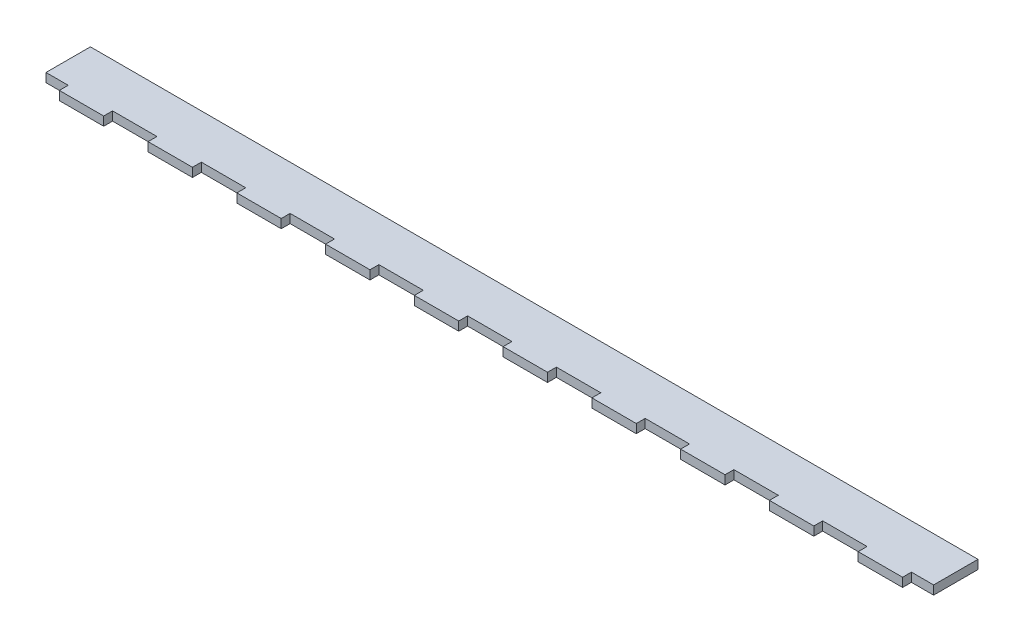
from build123d import *

# Parameters (mm, degrees)
BOSS_EXTRUDE1_DEPTH = 5.08


with BuildPart() as part:
    # Sketch1 → Boss-Extrude1 (new body)
    with BuildSketch(Plane(origin=(0, 0, 0), x_dir=(1, 0, 0), z_dir=(0, 1, 0))):
        Polygon((-190.5, -12.7), (-190.5, -17.78), (-165.1, -17.78), (-165.1, -12.7), (-139.7, -12.7), (-139.7, -17.78), (-114.3, -17.78), (-114.3, -12.7), (-88.9, -12.7), (-88.9, -17.78), (-63.5, -17.78), (-63.5, -12.7), (-38.1, -12.7), (-38.1, -17.78), (-12.7, -17.78), (-12.7, -12.7), (12.7, -12.7), (12.7, -17.78), (38.1, -17.78), (38.1, -12.7), (63.5, -12.7), (63.5, -17.78), (88.9, -17.78), (88.9, -12.7), (114.3, -12.7), (114.3, -17.78), (139.7, -17.78), (139.7, -12.7), (165.1, -12.7), (165.1, -17.78), (190.5, -17.78), (190.5, -12.7), (215.9, -12.7), (215.9, -17.78), (241.3, -17.78), (241.3, -12.7), (254, -12.7), (254, 12.7), (-254, 12.7), (-254, -12.7), (-241.3, -12.7), (-241.3, -17.78), (-215.9, -17.78), (-215.9, -12.7), align=None)
    extrude(amount=BOSS_EXTRUDE1_DEPTH)


solid = part.part
